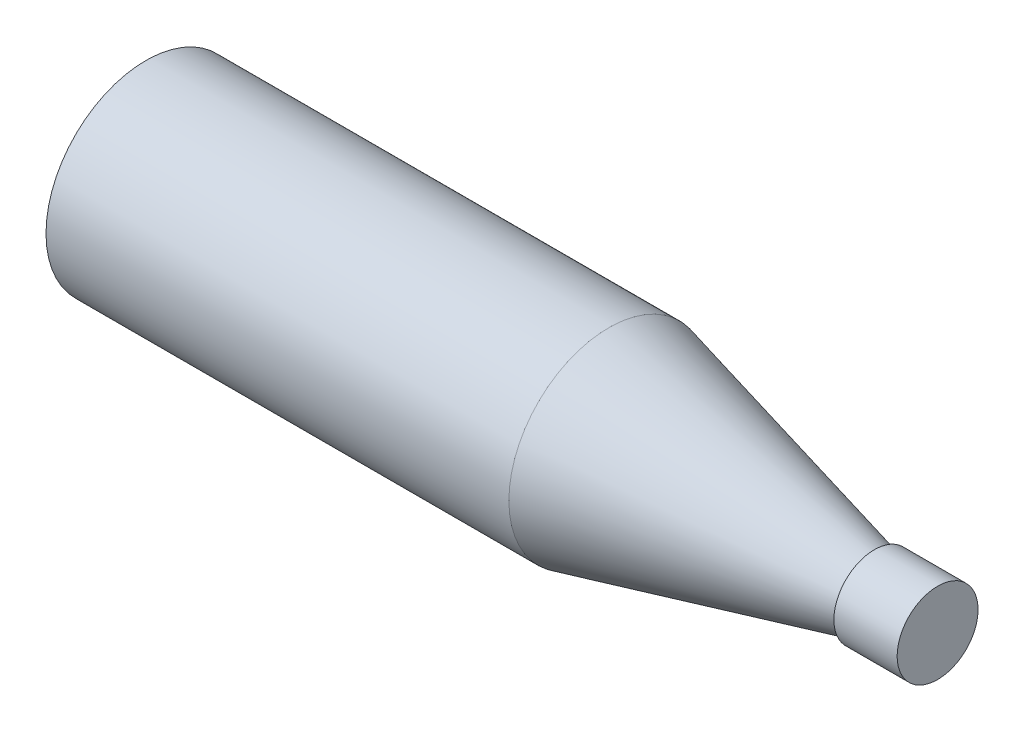
from build123d import *


with BuildPart() as part:
    # Эскиз1 → Повернуть2 (revolve)
    with BuildSketch(Plane.XY, mode=Mode.PRIVATE) as revolve_2_sk:
        Polygon((-50.774937895, 0), (-50.774937895, 39.5), (132.225062105, 39.5), (237.225062105, 13.5), (237.225062105, 16), (262.225062105, 16), (262.225062105, 0), align=None)
    revolve(revolve_2_sk.sketch.rotate(Axis((-50.774937895, 0, 0), (1, 0, 0)), 90), axis=Axis((-50.774937895, 0, 0), (1, 0, 0)))  # turned: the seam where the file's is


solid = part.part
